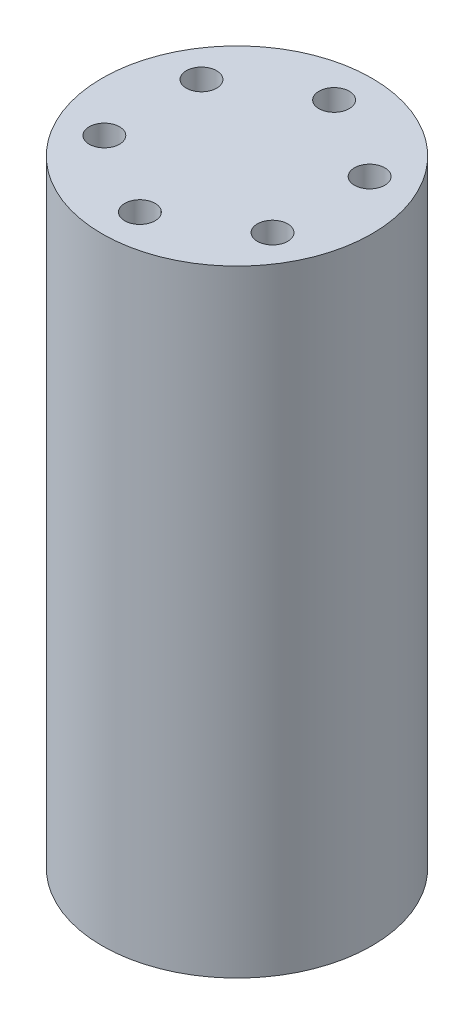
from build123d import *

# Parameters (mm, degrees)
SKETCH1_R             = 11.1125
BOSS_EXTRUDE1_DEPTH   = 50.8
M3X0_5_TAPPED_HOLE1_D = 2.5


with BuildPart() as part:
    # Sketch1 → Boss-Extrude1 (new body)
    with BuildSketch(Plane(origin=(0, 0, 0), x_dir=(1, 0, 0), z_dir=(0, 1, 0))):
        Circle(SKETCH1_R)
    extrude(amount=BOSS_EXTRUDE1_DEPTH)

    # M3x0.5 Tapped Hole1 (through all)
    with Locations(Plane(origin=(0, 50.8, 0), x_dir=(1, 0, 0), z_dir=(0, 1, 0))):
        with Locations((0, 8), (6.92820323, 4), (6.92820323, -4), (0, -8), (-6.92820323, -4), (-6.92820323, 4)):
            Hole(M3X0_5_TAPPED_HOLE1_D / 2)


solid = part.part
